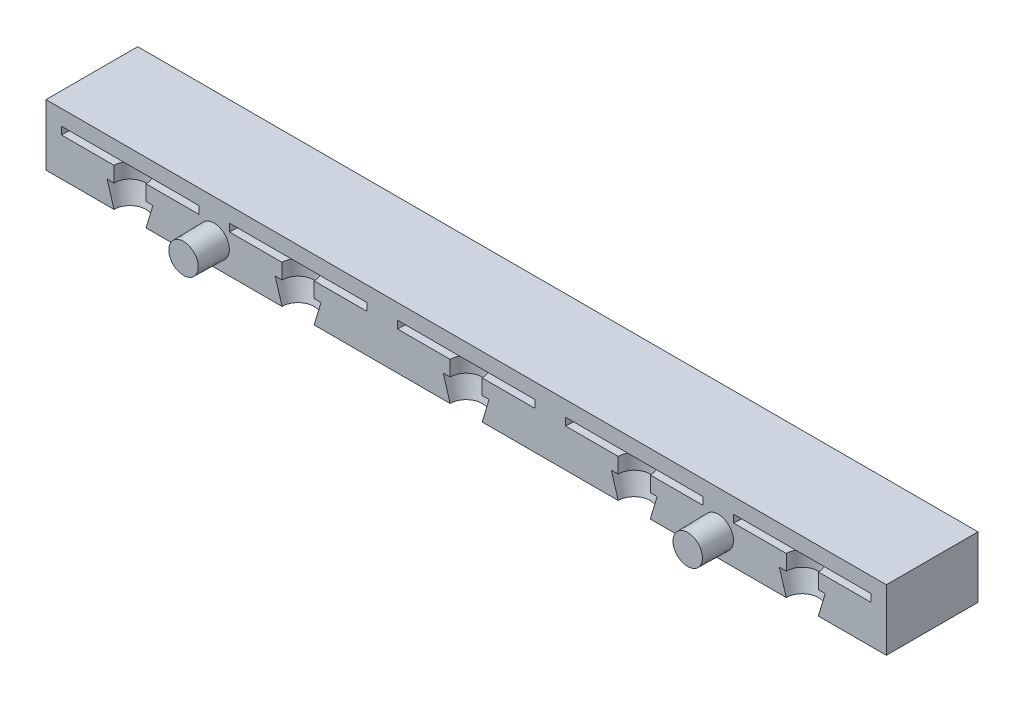
from build123d import *

# Parameters (mm, degrees)
SKETCH2_W           = 110
SKETCH2_H           = 8
BOSS_EXTRUDE1_DEPTH = 12
LPATTERN1_COUNT     = 5
LPATTERN1_PITCH     = 22
SKETCH4_R           = 2
BOSS_EXTRUDE2_DEPTH = 4
BOSS_EXTRUDE2_TAPER = 1


with BuildPart() as part:
    # Sketch2 → Boss-Extrude1 (new body)
    with BuildSketch(Plane.XY):
        with Locations((55, 4)):
            Rectangle(SKETCH2_W, SKETCH2_H)
    extrude(amount=-BOSS_EXTRUDE1_DEPTH)

    # Sketch3 → Cut-Revolve1 (revolve, cut)
    with BuildSketch(Plane.XY):
        Polygon((8, 3), (8.9, 3), (8.9, 5), (2, 5), (2, 6), (11, 6), (11, 0), (8.9, 0), align=None)
    cut_revolve1 = revolve(axis=Axis((11, 6, 0), (0, -1, 0)), mode=Mode.SUBTRACT)

    # LPattern1: Cut-Revolve1 ×5
    with Locations(*[(i * LPATTERN1_PITCH, 0, 0) for i in range(1, LPATTERN1_COUNT)]):
        add(cut_revolve1, mode=Mode.SUBTRACT)

    # Sketch4 → Boss-Extrude2 (add)
    with BuildSketch(Plane.XY):
        with Locations((22, 3)):
            Circle(SKETCH4_R)
        with Locations((88, 3)):
            Circle(SKETCH4_R)
    extrude(amount=BOSS_EXTRUDE2_DEPTH, taper=BOSS_EXTRUDE2_TAPER)


solid = part.part
